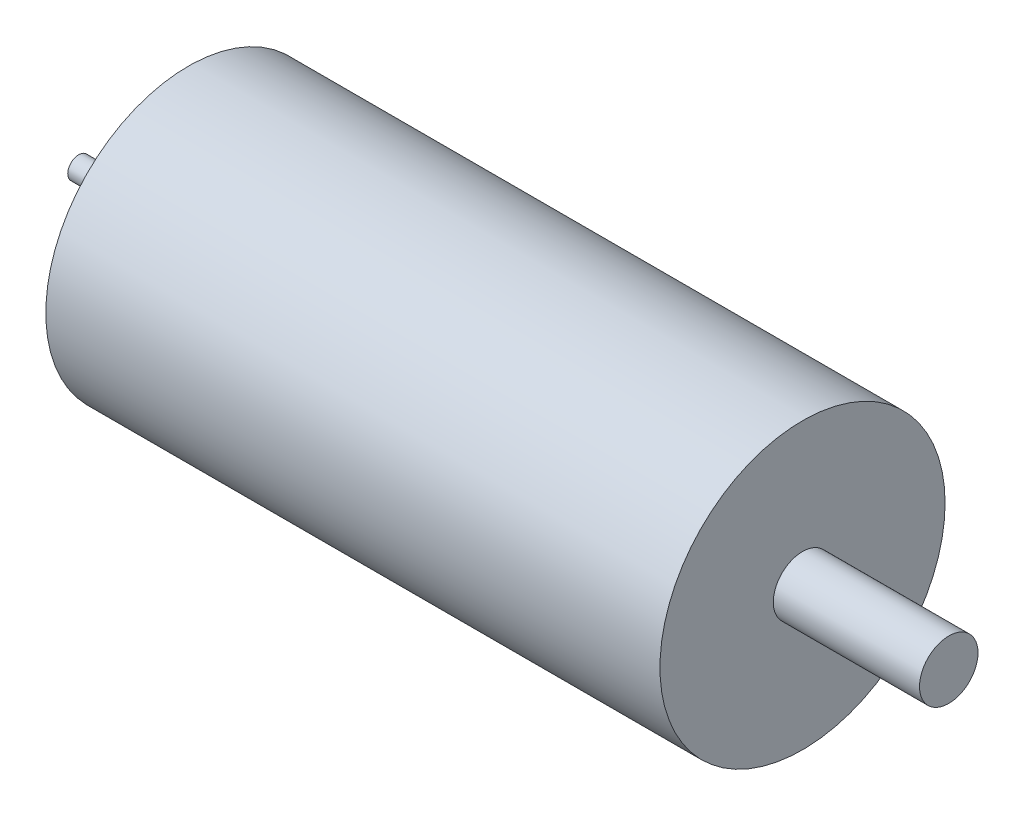
from build123d import *

# Parameters (mm, degrees)
SKETCH1_R           = 19.5
BOSS_EXTRUDE1_DEPTH = 84
SKETCH2_R           = 4
BOSS_EXTRUDE2_DEPTH = 20
SKETCH3_R           = 1.5
BOSS_EXTRUDE3_DEPTH = 15


with BuildPart() as part:
    # Sketch1 → Boss-Extrude1 (new body)
    with BuildSketch(Plane(origin=(0, 0, 0), x_dir=(0, 0, -1), z_dir=(1, 0, 0))):
        Circle(SKETCH1_R)
    extrude(amount=BOSS_EXTRUDE1_DEPTH)

    # Sketch2 → Boss-Extrude2 (add)
    with BuildSketch(Plane(origin=(84, 0, 0), x_dir=(0, 0, -1), z_dir=(1, 0, 0))):
        Circle(SKETCH2_R)
    extrude(amount=BOSS_EXTRUDE2_DEPTH)

    # Sketch3 → Boss-Extrude3 (add)
    with BuildSketch(Plane.ZY):
        Circle(SKETCH3_R)
    extrude(amount=BOSS_EXTRUDE3_DEPTH)


solid = part.part
